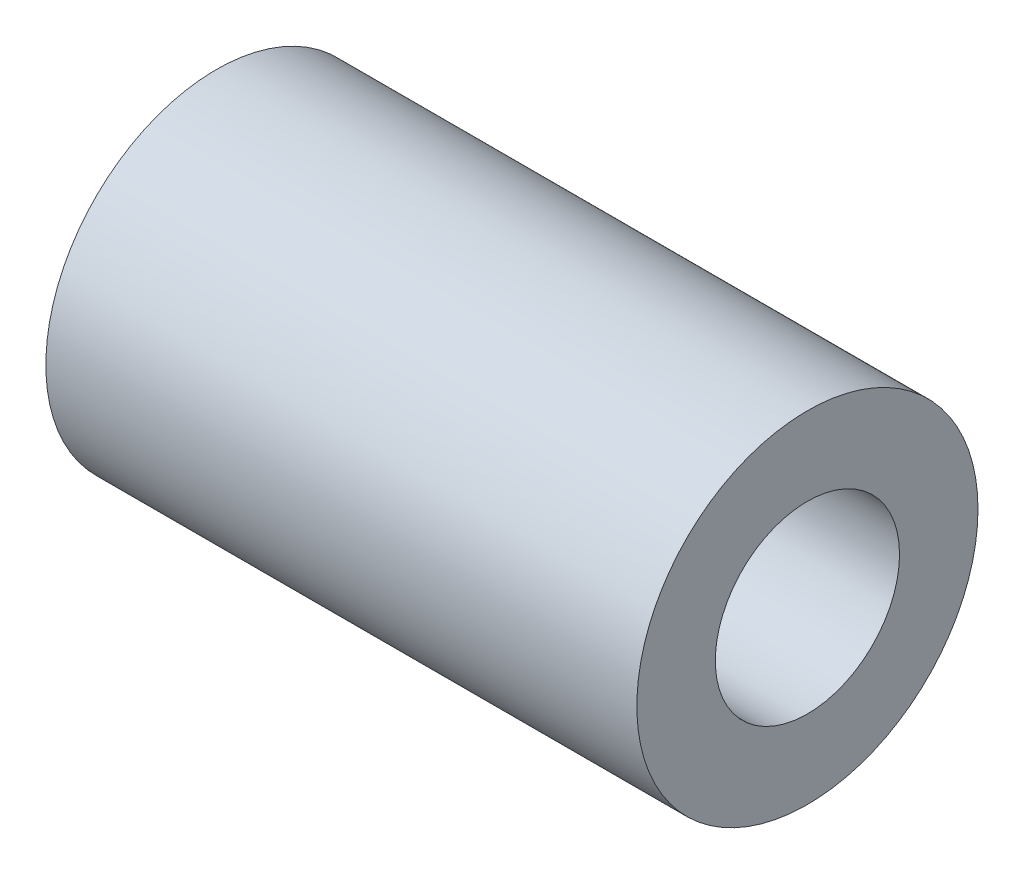
from build123d import *

# Parameters (mm, degrees)
ESQUISSE1_R        = 6.35
ESQUISSE1_R_2      = 3.429
BOSS_EXTRU_1_DEPTH = 22


with BuildPart() as part:
    # Esquisse1 → Boss.-Extru.1 (new body)
    with BuildSketch(Plane(origin=(0, 0, 0), x_dir=(0, 0, -1), z_dir=(1, 0, 0))):
        Circle(ESQUISSE1_R)
        Circle(ESQUISSE1_R_2, mode=Mode.SUBTRACT)
    extrude(amount=-BOSS_EXTRU_1_DEPTH)


solid = part.part
